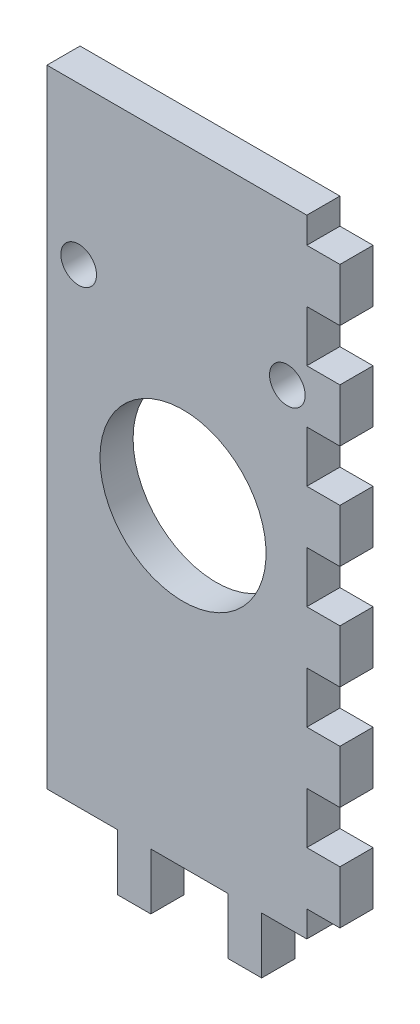
from build123d import *

# Parameters (mm, degrees)
SKETCH1_W           = 24.825
SKETCH1_H           = 3.175
SKETCH1_W_2         = 3.175
SKETCH1_H_2         = 24.825
BOSS_EXTRUDE1_DEPTH = 60
SKETCH2_W           = 3.125
SKETCH2_H           = 5.4
BOSS_EXTRUDE4_DEPTH = 3.175
SKETCH4_R           = 8
CUT_EXTRUDE1_DEPTH  = 3.175
SKETCH3_R           = 8
CUT_EXTRUDE2_DEPTH  = 3.175
SKETCH5_W           = 3.175
SKETCH5_H           = 5.4
BOSS_EXTRUDE5_DEPTH = 3.175
SKETCH6_R           = 1.75
CUT_EXTRUDE3_DEPTH  = 10
SKETCH7_R           = 1.75
CUT_EXTRUDE4_DEPTH  = 10
SKETCH8_W           = 3.175
SKETCH8_H           = 65.4
CUT_EXTRUDE6_DEPTH  = 24.825
SKETCH9_W           = 3.175
SKETCH9_H           = 2.5
SKETCH9_H_2         = 5
CUT_EXTRUDE8_DEPTH  = 10
SKETCH10_R          = 1.70936
SKETCH10_R_2        = 7.95936
BOSS_EXTRUDE6_DEPTH = 3.175


with BuildPart() as part:
    # Sketch1 → Boss-Extrude1 (new body)
    with BuildSketch(Plane(origin=(0, 0, 0), x_dir=(1, 0, 0), z_dir=(0, 1, 0))):
        with Locations((-38.0875, 24.0875)):
            Rectangle(SKETCH1_W, SKETCH1_H)
        with Locations((-24.0875, 24.0875)):
            Rectangle(SKETCH1_W_2, SKETCH1_H)
        with Locations((-24.0875, 38.0875)):
            Rectangle(SKETCH1_W_2, SKETCH1_H_2)
    extrude(amount=BOSS_EXTRUDE1_DEPTH)

    # Sketch2 → Boss-Extrude4 (add)
    with BuildSketch(Plane.XY.offset(-22.5)):
        with Locations((-42.1875, -2.7)):
            Rectangle(SKETCH2_W, SKETCH2_H)
        with Locations((-31.5625, -2.7)):
            Rectangle(SKETCH2_W, SKETCH2_H)
    extrude(amount=-BOSS_EXTRUDE4_DEPTH)

    # Sketch4 → Cut-Extrude1 (cut)
    with BuildSketch(Plane.XY.offset(-22.5)):
        with Locations((-37.5, 30)):
            Circle(SKETCH4_R)
    extrude(amount=-CUT_EXTRUDE1_DEPTH, mode=Mode.SUBTRACT)

    # Sketch3 → Cut-Extrude2 (cut)
    with BuildSketch(Plane(origin=(-22.5, 0, 0), x_dir=(0, 0, -1), z_dir=(1, 0, 0))):
        with Locations((37.5, 30)):
            Circle(SKETCH3_R)
    extrude(amount=-CUT_EXTRUDE2_DEPTH, mode=Mode.SUBTRACT)

    # Sketch5 → Boss-Extrude5 (add)
    with BuildSketch(Plane(origin=(-22.5, 0, 0), x_dir=(0, 0, -1), z_dir=(1, 0, 0))):
        with Locations((42.2625, -2.7)):
            Rectangle(SKETCH5_W, SKETCH5_H)
        with Locations((31.5875, -2.7)):
            Rectangle(SKETCH5_W, SKETCH5_H)
    extrude(amount=-BOSS_EXTRUDE5_DEPTH)

    # Sketch6 → Cut-Extrude3 (cut)
    with BuildSketch(Plane.XY.offset(-22.5)):
        with Locations((-47.5, 45)):
            Circle(SKETCH6_R)
        with Locations((-27.5, 45)):
            Circle(SKETCH6_R)
    extrude(amount=-CUT_EXTRUDE3_DEPTH, mode=Mode.SUBTRACT)

    # Sketch7 → Cut-Extrude4 (cut)
    with BuildSketch(Plane(origin=(-22.5, 0, 0), x_dir=(0, 0, -1), z_dir=(1, 0, 0))):
        with Locations((47.5, 45)):
            Circle(SKETCH7_R)
        with Locations((27.5, 45)):
            Circle(SKETCH7_R)
    extrude(amount=-CUT_EXTRUDE4_DEPTH, mode=Mode.SUBTRACT)

    # Sketch8 → Cut-Extrude6 (cut)
    with BuildSketch(Plane(origin=(0, 0, -50.5), x_dir=(-1, 0, 0), z_dir=(0, 0, -1))):
        with Locations((24.0875, 27.3)):
            Rectangle(SKETCH8_W, SKETCH8_H)
    extrude(amount=-CUT_EXTRUDE6_DEPTH, mode=Mode.SUBTRACT)

    # Sketch9 → Cut-Extrude8 (cut)
    with BuildSketch(Plane(origin=(0, 0, -25.675), x_dir=(-1, 0, 0), z_dir=(0, 0, -1))):
        with Locations((24.0875, 58.75)):
            Rectangle(SKETCH9_W, SKETCH9_H)
        with Locations((24.0875, 50)):
            Rectangle(SKETCH9_W, SKETCH9_H_2)
        with Locations((24.0875, 40)):
            Rectangle(SKETCH9_W, SKETCH9_H_2)
        with Locations((24.0875, 30)):
            Rectangle(SKETCH9_W, SKETCH9_H_2)
        with Locations((24.0875, 20)):
            Rectangle(SKETCH9_W, SKETCH9_H_2)
        with Locations((24.0875, 10)):
            Rectangle(SKETCH9_W, SKETCH9_H_2)
        with Locations((24.0875, 1.25)):
            Rectangle(SKETCH9_W, SKETCH9_H)
    extrude(amount=-CUT_EXTRUDE8_DEPTH, mode=Mode.SUBTRACT)

    # Sketch10 → Boss-Extrude6 (add)
    with BuildSketch(Plane(origin=(0, 0, -25.675), x_dir=(-1, 0, 0), z_dir=(0, 0, -1))):
        Polygon((25.63436, 60.04064), (25.63436, 57.54064), (22.45936, 57.54064), (22.45936, 52.45936), (25.63436, 52.45936), (25.63436, 47.54064), (22.45936, 47.54064), (22.45936, 42.45936), (25.63436, 42.45936), (25.63436, 37.54064), (22.45936, 37.54064), (22.45936, 32.45936), (25.63436, 32.45936), (25.63436, 27.54064), (22.45936, 27.54064), (22.45936, 22.45936), (25.63436, 22.45936), (25.63436, 17.54064), (22.45936, 17.54064), (22.45936, 12.45936), (25.63436, 12.45936), (25.63436, 7.54064), (22.45936, 7.54064), (22.45936, 2.45936), (25.63436, 2.45936), (25.63436, -0.04064), (29.95936, -0.04064), (29.95936, -5.44064), (33.16564, -5.44064), (33.16564, -0.04064), (40.58436, -0.04064), (40.58436, -5.44064), (43.79064, -5.44064), (43.79064, -0.04064), (50.54064, -0.04064), (50.54064, 60.04064), align=None)
        with Locations((27.5, 45)):
            Circle(SKETCH10_R, mode=Mode.SUBTRACT)
        with Locations((47.5, 45)):
            Circle(SKETCH10_R, mode=Mode.SUBTRACT)
        with Locations((37.5, 30)):
            Circle(SKETCH10_R_2, mode=Mode.SUBTRACT)
    extrude(amount=-BOSS_EXTRUDE6_DEPTH)


solid = part.part
